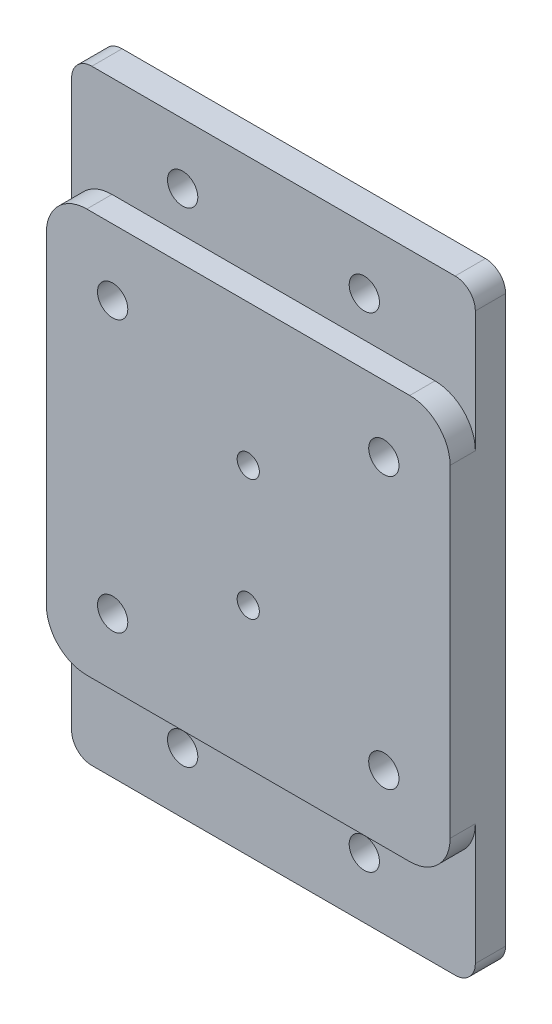
from build123d import *

# Parameters (mm, degrees)
SKETCH_2_W               = 40
SKETCH_2_H               = 40
EXTRUDE_1_DEPTH          = 2.5
SKETCH_5_W               = 40
SKETCH_5_H               = 60
SKETCH_5_R               = 1.5
EXTRUDE_2_DEPTH          = 3
SKETCH_4_R               = 1.5
SKETCH_4_R_2             = 1.10000034
CUT_EXTRUDE_1_DEPTH      = 6.5
FILLET_1_R               = 4
FILLET_5_R               = 2
SKETCH_6_R               = 3
CUT_EXTRUDE_2_DEPTH      = 3
MIRROR_2_COPY_1_SKETCH_R = 3
MIRROR_2_COPY_1_DEPTH    = 3
SKETCH_7_R               = 2
CUT_EXTRUDE_3_DEPTH      = 3


with BuildPart() as part:
    # 草图2 → 凸台-拉伸1 (new body)
    with BuildSketch(Plane.XY):
        with Locations((-45.062828034, 6.935543198)):
            Rectangle(SKETCH_2_W, SKETCH_2_H)
    extrude(amount=EXTRUDE_1_DEPTH)

    # 草图5 → 凸台-拉伸2 (add)
    with BuildSketch(Plane(origin=(0, 0, 0), x_dir=(-1, 0, 0), z_dir=(0, 0, -1))):
        with Locations((45.062828034, 6.935543198)):
            Rectangle(SKETCH_5_W, SKETCH_5_H)
        with Locations((36.062828034, 30.935543198)):
            Circle(SKETCH_5_R, mode=Mode.SUBTRACT)
        with Locations((54.062828034, 30.935543198)):
            Circle(SKETCH_5_R, mode=Mode.SUBTRACT)
        with Locations((54.062828034, -17.064456802)):
            Circle(SKETCH_5_R, mode=Mode.SUBTRACT)
        with Locations((36.062828034, -17.064456802)):
            Circle(SKETCH_5_R, mode=Mode.SUBTRACT)
    extrude(amount=EXTRUDE_2_DEPTH)

    # 草图4 → 切除-拉伸1 (cut, through all)
    with BuildSketch(Plane.XY.offset(2.5)):
        with Locations((-31.627799192, 20.370572041)):
            Circle(SKETCH_4_R)
        with Locations((-58.497856877, 20.370572041)):
            Circle(SKETCH_4_R)
        with Locations((-58.497856877, -6.499485644)):
            Circle(SKETCH_4_R)
        with Locations((-31.627799192, -6.499485644)):
            Circle(SKETCH_4_R)
        with Locations((-45.062828034, 12.935531198)):
            Circle(SKETCH_4_R_2)
        with Locations((-45.062828034, 0.935555198)):
            Circle(SKETCH_4_R_2)
    extrude(amount=-CUT_EXTRUDE_1_DEPTH, mode=Mode.SUBTRACT)

    # 圆角1
    fillet_1_edges = [part.edges().sort_by_distance(p)[0] for p in [
        (-25.062828034, -13.064456802, 1.25),
        (-65.062828034, -13.064456802, 1.25),
        (-65.062828034, 26.935543198, 1.25),
        (-25.062828034, 26.935543198, 1.25),
    ]]
    fillet(fillet_1_edges, radius=FILLET_1_R)

    # 圆角5
    fillet_5_edges = [part.edges().sort_by_distance(p)[0] for p in [
        (-25.062828034, 36.935543198, -1.5),
        (-25.062828034, -23.064456802, -1.5),
        (-65.062828034, -23.064456802, -1.5),
        (-65.062828034, 36.935543198, -1.5),
    ]]
    fillet(fillet_5_edges, radius=FILLET_5_R)

    # 草图6 → 切除-拉伸2 (cut)
    with BuildSketch(Plane(origin=(0, 0, -3), x_dir=(-1, 0, 0), z_dir=(0, 0, -1))):
        with Locations((58.497856877, 20.370572041)):
            Circle(SKETCH_6_R)
    cut_extrude_2 = extrude(amount=-CUT_EXTRUDE_2_DEPTH, mode=Mode.SUBTRACT)

    # 镜向1: 切除-拉伸2 across plane
    add(cut_extrude_2.mirror(Plane.ZX.offset(6.935543198)), mode=Mode.SUBTRACT)

    # 镜向2: 切除-拉伸2 across plane
    add(cut_extrude_2.mirror(Plane.ZY.offset(45.062828034)), mode=Mode.SUBTRACT)

    # 镜向2 copy 1 sketch → 镜向2 copy 1 (cut)
    with BuildSketch(Plane(origin=(-90.125656068, 13.871086397, -3), x_dir=(1, 0, 0), z_dir=(0, 0, -1))):
        with Locations((58.497856877, 20.370572041)):
            Circle(MIRROR_2_COPY_1_SKETCH_R)
    extrude(amount=-MIRROR_2_COPY_1_DEPTH, mode=Mode.SUBTRACT)

    # 草图7 → 切除-拉伸3 (cut)
    with BuildSketch(Plane(origin=(0, 0, -3), x_dir=(-1, 0, 0), z_dir=(0, 0, -1))):
        with Locations((45.062828034, 12.935531198)):
            Circle(SKETCH_7_R)
        with Locations((45.062828034, 0.935555198)):
            Circle(SKETCH_7_R)
    extrude(amount=-CUT_EXTRUDE_3_DEPTH, mode=Mode.SUBTRACT)


solid = part.part
